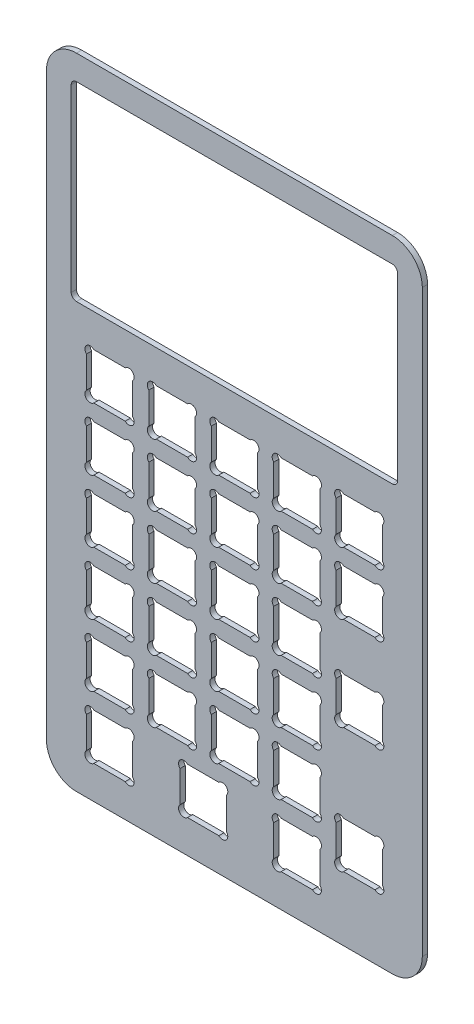
from build123d import *

# Parameters (mm, degrees)
SKETCH1_W           = 113.9
SKETCH1_H           = 193.7954
BOSS_EXTRUDE1_DEPTH = 1.5875
FILLET1_R           = 9.0875


with BuildPart() as part:
    # Sketch1 → Boss-Extrude1 (new body)
    with BuildSketch(Plane.XY):
        with Locations((-56.95, 96.8977)):
            Rectangle(SKETCH1_W, SKETCH1_H)
        with BuildLine():
            Line((-80.62263597, 118.5954), (-71.11736403, 118.5954))
            ThreePointArc((-71.11736403, 118.5954), (-68.8723, 118.5954), (-68.8723, 116.35033597))
            Line((-68.8723, 116.35033597), (-68.8723, 106.84506403))
            ThreePointArc((-68.8723, 106.84506403), (-68.8723, 104.6), (-71.11736403, 104.6))
            Line((-71.11736403, 104.6), (-80.62263597, 104.6))
            ThreePointArc((-80.62263597, 104.6), (-82.8677, 104.6), (-82.8677, 106.84506403))
            Line((-82.8677, 106.84506403), (-82.8677, 116.35033597))
            ThreePointArc((-82.8677, 116.35033597), (-82.8677, 118.5954), (-80.62263597, 118.5954))
        make_face(mode=Mode.SUBTRACT)
        with BuildLine():
            Line((-99.54263597, 118.5954), (-90.03736403, 118.5954))
            ThreePointArc((-90.03736403, 118.5954), (-87.7923, 118.5954), (-87.7923, 116.35033597))
            Line((-87.7923, 116.35033597), (-87.7923, 106.84506403))
            ThreePointArc((-87.7923, 106.84506403), (-87.7923, 104.6), (-90.03736403, 104.6))
            Line((-90.03736403, 104.6), (-99.54263597, 104.6))
            ThreePointArc((-99.54263597, 104.6), (-101.7877, 104.6), (-101.7877, 106.84506403))
            Line((-101.7877, 106.84506403), (-101.7877, 116.35033597))
            ThreePointArc((-101.7877, 116.35033597), (-101.7877, 118.5954), (-99.54263597, 118.5954))
        make_face(mode=Mode.SUBTRACT)
        with BuildLine():
            Line((-61.70263597, 118.5954), (-52.19736403, 118.5954))
            ThreePointArc((-52.19736403, 118.5954), (-49.9523, 118.5954), (-49.9523, 116.35033597))
            Line((-49.9523, 116.35033597), (-49.9523, 106.84506403))
            ThreePointArc((-49.9523, 106.84506403), (-49.9523, 104.6), (-52.19736403, 104.6))
            Line((-52.19736403, 104.6), (-61.70263597, 104.6))
            ThreePointArc((-61.70263597, 104.6), (-63.9477, 104.6), (-63.9477, 106.84506403))
            Line((-63.9477, 106.84506403), (-63.9477, 116.35033597))
            ThreePointArc((-63.9477, 116.35033597), (-63.9477, 118.5954), (-61.70263597, 118.5954))
        make_face(mode=Mode.SUBTRACT)
        with BuildLine():
            Line((-42.78263597, 118.5954), (-33.27736403, 118.5954))
            ThreePointArc((-33.27736403, 118.5954), (-31.0323, 118.5954), (-31.0323, 116.35033597))
            Line((-31.0323, 116.35033597), (-31.0323, 106.84506403))
            ThreePointArc((-31.0323, 106.84506403), (-31.0323, 104.6), (-33.27736403, 104.6))
            Line((-33.27736403, 104.6), (-42.78263597, 104.6))
            ThreePointArc((-42.78263597, 104.6), (-45.0277, 104.6), (-45.0277, 106.84506403))
            Line((-45.0277, 106.84506403), (-45.0277, 116.35033597))
            ThreePointArc((-45.0277, 116.35033597), (-45.0277, 118.5954), (-42.78263597, 118.5954))
        make_face(mode=Mode.SUBTRACT)
        with BuildLine():
            Line((-23.86263597, 118.5954), (-14.35736403, 118.5954))
            ThreePointArc((-14.35736403, 118.5954), (-12.1123, 118.5954), (-12.1123, 116.35033597))
            Line((-12.1123, 116.35033597), (-12.1123, 106.84506403))
            ThreePointArc((-12.1123, 106.84506403), (-12.1123, 104.6), (-14.35736403, 104.6))
            Line((-14.35736403, 104.6), (-23.86263597, 104.6))
            ThreePointArc((-23.86263597, 104.6), (-26.1077, 104.6), (-26.1077, 106.84506403))
            Line((-26.1077, 106.84506403), (-26.1077, 116.35033597))
            ThreePointArc((-26.1077, 116.35033597), (-26.1077, 118.5954), (-23.86263597, 118.5954))
        make_face(mode=Mode.SUBTRACT)
        with BuildLine():
            Line((-80.62263597, 99.6754), (-71.11736403, 99.6754))
            ThreePointArc((-71.11736403, 99.6754), (-68.8723, 99.6754), (-68.8723, 97.43033597))
            Line((-68.8723, 97.43033597), (-68.8723, 87.92506403))
            ThreePointArc((-68.8723, 87.92506403), (-68.8723, 85.68), (-71.11736403, 85.68))
            Line((-71.11736403, 85.68), (-80.62263597, 85.68))
            ThreePointArc((-80.62263597, 85.68), (-82.8677, 85.68), (-82.8677, 87.92506403))
            Line((-82.8677, 87.92506403), (-82.8677, 97.43033597))
            ThreePointArc((-82.8677, 97.43033597), (-82.8677, 99.6754), (-80.62263597, 99.6754))
        make_face(mode=Mode.SUBTRACT)
        with BuildLine():
            Line((-61.70263597, 99.6754), (-52.19736403, 99.6754))
            ThreePointArc((-52.19736403, 99.6754), (-49.9523, 99.6754), (-49.9523, 97.43033597))
            Line((-49.9523, 97.43033597), (-49.9523, 87.92506403))
            ThreePointArc((-49.9523, 87.92506403), (-49.9523, 85.68), (-52.19736403, 85.68))
            Line((-52.19736403, 85.68), (-61.70263597, 85.68))
            ThreePointArc((-61.70263597, 85.68), (-63.9477, 85.68), (-63.9477, 87.92506403))
            Line((-63.9477, 87.92506403), (-63.9477, 97.43033597))
            ThreePointArc((-63.9477, 97.43033597), (-63.9477, 99.6754), (-61.70263597, 99.6754))
        make_face(mode=Mode.SUBTRACT)
        with BuildLine():
            Line((-42.78263597, 99.6754), (-33.27736403, 99.6754))
            ThreePointArc((-33.27736403, 99.6754), (-31.0323, 99.6754), (-31.0323, 97.43033597))
            Line((-31.0323, 97.43033597), (-31.0323, 87.92506403))
            ThreePointArc((-31.0323, 87.92506403), (-31.0323, 85.68), (-33.27736403, 85.68))
            Line((-33.27736403, 85.68), (-42.78263597, 85.68))
            ThreePointArc((-42.78263597, 85.68), (-45.0277, 85.68), (-45.0277, 87.92506403))
            Line((-45.0277, 87.92506403), (-45.0277, 97.43033597))
            ThreePointArc((-45.0277, 97.43033597), (-45.0277, 99.6754), (-42.78263597, 99.6754))
        make_face(mode=Mode.SUBTRACT)
        with BuildLine():
            Line((-23.86263597, 99.6754), (-14.35736403, 99.6754))
            ThreePointArc((-14.35736403, 99.6754), (-12.1123, 99.6754), (-12.1123, 97.43033597))
            Line((-12.1123, 97.43033597), (-12.1123, 87.92506403))
            ThreePointArc((-12.1123, 87.92506403), (-12.1123, 85.68), (-14.35736403, 85.68))
            Line((-14.35736403, 85.68), (-23.86263597, 85.68))
            ThreePointArc((-23.86263597, 85.68), (-26.1077, 85.68), (-26.1077, 87.92506403))
            Line((-26.1077, 87.92506403), (-26.1077, 97.43033597))
            ThreePointArc((-26.1077, 97.43033597), (-26.1077, 99.6754), (-23.86263597, 99.6754))
        make_face(mode=Mode.SUBTRACT)
        with BuildLine():
            Line((-80.62263597, 80.7554), (-71.11736403, 80.7554))
            ThreePointArc((-71.11736403, 80.7554), (-68.8723, 80.7554), (-68.8723, 78.51033597))
            Line((-68.8723, 78.51033597), (-68.8723, 69.00506403))
            ThreePointArc((-68.8723, 69.00506403), (-68.8723, 66.76), (-71.11736403, 66.76))
            Line((-71.11736403, 66.76), (-80.62263597, 66.76))
            ThreePointArc((-80.62263597, 66.76), (-82.8677, 66.76), (-82.8677, 69.00506403))
            Line((-82.8677, 69.00506403), (-82.8677, 78.51033597))
            ThreePointArc((-82.8677, 78.51033597), (-82.8677, 80.7554), (-80.62263597, 80.7554))
        make_face(mode=Mode.SUBTRACT)
        with BuildLine():
            Line((-61.70263597, 80.7554), (-52.19736403, 80.7554))
            ThreePointArc((-52.19736403, 80.7554), (-49.9523, 80.7554), (-49.9523, 78.51033597))
            Line((-49.9523, 78.51033597), (-49.9523, 69.00506403))
            ThreePointArc((-49.9523, 69.00506403), (-49.9523, 66.76), (-52.19736403, 66.76))
            Line((-52.19736403, 66.76), (-61.70263597, 66.76))
            ThreePointArc((-61.70263597, 66.76), (-63.9477, 66.76), (-63.9477, 69.00506403))
            Line((-63.9477, 69.00506403), (-63.9477, 78.51033597))
            ThreePointArc((-63.9477, 78.51033597), (-63.9477, 80.7554), (-61.70263597, 80.7554))
        make_face(mode=Mode.SUBTRACT)
        with BuildLine():
            Line((-42.78263597, 80.7554), (-33.27736403, 80.7554))
            ThreePointArc((-33.27736403, 80.7554), (-31.0323, 80.7554), (-31.0323, 78.51033597))
            Line((-31.0323, 78.51033597), (-31.0323, 69.00506403))
            ThreePointArc((-31.0323, 69.00506403), (-31.0323, 66.76), (-33.27736403, 66.76))
            Line((-33.27736403, 66.76), (-42.78263597, 66.76))
            ThreePointArc((-42.78263597, 66.76), (-45.0277, 66.76), (-45.0277, 69.00506403))
            Line((-45.0277, 69.00506403), (-45.0277, 78.51033597))
            ThreePointArc((-45.0277, 78.51033597), (-45.0277, 80.7554), (-42.78263597, 80.7554))
        make_face(mode=Mode.SUBTRACT)
        with BuildLine():
            Line((-80.62263597, 61.8354), (-71.11736403, 61.8354))
            ThreePointArc((-71.11736403, 61.8354), (-68.8723, 61.8354), (-68.8723, 59.59033597))
            Line((-68.8723, 59.59033597), (-68.8723, 50.08506403))
            ThreePointArc((-68.8723, 50.08506403), (-68.8723, 47.84), (-71.11736403, 47.84))
            Line((-71.11736403, 47.84), (-80.62263597, 47.84))
            ThreePointArc((-80.62263597, 47.84), (-82.8677, 47.84), (-82.8677, 50.08506403))
            Line((-82.8677, 50.08506403), (-82.8677, 59.59033597))
            ThreePointArc((-82.8677, 59.59033597), (-82.8677, 61.8354), (-80.62263597, 61.8354))
        make_face(mode=Mode.SUBTRACT)
        with BuildLine():
            Line((-61.70263597, 61.8354), (-52.19736403, 61.8354))
            ThreePointArc((-52.19736403, 61.8354), (-49.9523, 61.8354), (-49.9523, 59.59033597))
            Line((-49.9523, 59.59033597), (-49.9523, 50.08506403))
            ThreePointArc((-49.9523, 50.08506403), (-49.9523, 47.84), (-52.19736403, 47.84))
            Line((-52.19736403, 47.84), (-61.70263597, 47.84))
            ThreePointArc((-61.70263597, 47.84), (-63.9477, 47.84), (-63.9477, 50.08506403))
            Line((-63.9477, 50.08506403), (-63.9477, 59.59033597))
            ThreePointArc((-63.9477, 59.59033597), (-63.9477, 61.8354), (-61.70263597, 61.8354))
        make_face(mode=Mode.SUBTRACT)
        with BuildLine():
            Line((-42.78263597, 61.8354), (-33.27736403, 61.8354))
            ThreePointArc((-33.27736403, 61.8354), (-31.0323, 61.8354), (-31.0323, 59.59033597))
            Line((-31.0323, 59.59033597), (-31.0323, 50.08506403))
            ThreePointArc((-31.0323, 50.08506403), (-31.0323, 47.84), (-33.27736403, 47.84))
            Line((-33.27736403, 47.84), (-42.78263597, 47.84))
            ThreePointArc((-42.78263597, 47.84), (-45.0277, 47.84), (-45.0277, 50.08506403))
            Line((-45.0277, 50.08506403), (-45.0277, 59.59033597))
            ThreePointArc((-45.0277, 59.59033597), (-45.0277, 61.8354), (-42.78263597, 61.8354))
        make_face(mode=Mode.SUBTRACT)
        with BuildLine():
            Line((-80.62263597, 42.9154), (-71.11736403, 42.9154))
            ThreePointArc((-71.11736403, 42.9154), (-68.8723, 42.9154), (-68.8723, 40.67033597))
            Line((-68.8723, 40.67033597), (-68.8723, 31.16506403))
            ThreePointArc((-68.8723, 31.16506403), (-68.8723, 28.92), (-71.11736403, 28.92))
            Line((-71.11736403, 28.92), (-80.62263597, 28.92))
            ThreePointArc((-80.62263597, 28.92), (-82.8677, 28.92), (-82.8677, 31.16506403))
            Line((-82.8677, 31.16506403), (-82.8677, 40.67033597))
            ThreePointArc((-82.8677, 40.67033597), (-82.8677, 42.9154), (-80.62263597, 42.9154))
        make_face(mode=Mode.SUBTRACT)
        with BuildLine():
            Line((-61.70263597, 42.9154), (-52.19736403, 42.9154))
            ThreePointArc((-52.19736403, 42.9154), (-49.9523, 42.9154), (-49.9523, 40.67033597))
            Line((-49.9523, 40.67033597), (-49.9523, 31.16506403))
            ThreePointArc((-49.9523, 31.16506403), (-49.9523, 28.92), (-52.19736403, 28.92))
            Line((-52.19736403, 28.92), (-61.70263597, 28.92))
            ThreePointArc((-61.70263597, 28.92), (-63.9477, 28.92), (-63.9477, 31.16506403))
            Line((-63.9477, 31.16506403), (-63.9477, 40.67033597))
            ThreePointArc((-63.9477, 40.67033597), (-63.9477, 42.9154), (-61.70263597, 42.9154))
        make_face(mode=Mode.SUBTRACT)
        with BuildLine():
            Line((-42.78263597, 42.9154), (-33.27736403, 42.9154))
            ThreePointArc((-33.27736403, 42.9154), (-31.0323, 42.9154), (-31.0323, 40.67033597))
            Line((-31.0323, 40.67033597), (-31.0323, 31.16506403))
            ThreePointArc((-31.0323, 31.16506403), (-31.0323, 28.92), (-33.27736403, 28.92))
            Line((-33.27736403, 28.92), (-42.78263597, 28.92))
            ThreePointArc((-42.78263597, 28.92), (-45.0277, 28.92), (-45.0277, 31.16506403))
            Line((-45.0277, 31.16506403), (-45.0277, 40.67033597))
            ThreePointArc((-45.0277, 40.67033597), (-45.0277, 42.9154), (-42.78263597, 42.9154))
        make_face(mode=Mode.SUBTRACT)
        with BuildLine():
            Line((-42.78263597, 23.9954), (-33.27736403, 23.9954))
            ThreePointArc((-33.27736403, 23.9954), (-31.0323, 23.9954), (-31.0323, 21.75033597))
            Line((-31.0323, 21.75033597), (-31.0323, 12.24506403))
            ThreePointArc((-31.0323, 12.24506403), (-31.0323, 10), (-33.27736403, 10))
            Line((-33.27736403, 10), (-42.78263597, 10))
            ThreePointArc((-42.78263597, 10), (-45.0277, 10), (-45.0277, 12.24506403))
            Line((-45.0277, 12.24506403), (-45.0277, 21.75033597))
            ThreePointArc((-45.0277, 21.75033597), (-45.0277, 23.9954), (-42.78263597, 23.9954))
        make_face(mode=Mode.SUBTRACT)
        with BuildLine():
            Line((-99.54263597, 99.6754), (-90.03736403, 99.6754))
            ThreePointArc((-90.03736403, 99.6754), (-87.7923, 99.6754), (-87.7923, 97.43033597))
            Line((-87.7923, 97.43033597), (-87.7923, 87.92506403))
            ThreePointArc((-87.7923, 87.92506403), (-87.7923, 85.68), (-90.03736403, 85.68))
            Line((-90.03736403, 85.68), (-99.54263597, 85.68))
            ThreePointArc((-99.54263597, 85.68), (-101.7877, 85.68), (-101.7877, 87.92506403))
            Line((-101.7877, 87.92506403), (-101.7877, 97.43033597))
            ThreePointArc((-101.7877, 97.43033597), (-101.7877, 99.6754), (-99.54263597, 99.6754))
        make_face(mode=Mode.SUBTRACT)
        with BuildLine():
            Line((-99.54263597, 80.7554), (-90.03736403, 80.7554))
            ThreePointArc((-90.03736403, 80.7554), (-87.7923, 80.7554), (-87.7923, 78.51033597))
            Line((-87.7923, 78.51033597), (-87.7923, 69.00506403))
            ThreePointArc((-87.7923, 69.00506403), (-87.7923, 66.76), (-90.03736403, 66.76))
            Line((-90.03736403, 66.76), (-99.54263597, 66.76))
            ThreePointArc((-99.54263597, 66.76), (-101.7877, 66.76), (-101.7877, 69.00506403))
            Line((-101.7877, 69.00506403), (-101.7877, 78.51033597))
            ThreePointArc((-101.7877, 78.51033597), (-101.7877, 80.7554), (-99.54263597, 80.7554))
        make_face(mode=Mode.SUBTRACT)
        with BuildLine():
            Line((-99.54263597, 61.8354), (-90.03736403, 61.8354))
            ThreePointArc((-90.03736403, 61.8354), (-87.7923, 61.8354), (-87.7923, 59.59033597))
            Line((-87.7923, 59.59033597), (-87.7923, 50.08506403))
            ThreePointArc((-87.7923, 50.08506403), (-87.7923, 47.84), (-90.03736403, 47.84))
            Line((-90.03736403, 47.84), (-99.54263597, 47.84))
            ThreePointArc((-99.54263597, 47.84), (-101.7877, 47.84), (-101.7877, 50.08506403))
            Line((-101.7877, 50.08506403), (-101.7877, 59.59033597))
            ThreePointArc((-101.7877, 59.59033597), (-101.7877, 61.8354), (-99.54263597, 61.8354))
        make_face(mode=Mode.SUBTRACT)
        with BuildLine():
            Line((-99.54263597, 42.9154), (-90.03736403, 42.9154))
            ThreePointArc((-90.03736403, 42.9154), (-87.7923, 42.9154), (-87.7923, 40.67033597))
            Line((-87.7923, 40.67033597), (-87.7923, 31.16506403))
            ThreePointArc((-87.7923, 31.16506403), (-87.7923, 28.92), (-90.03736403, 28.92))
            Line((-90.03736403, 28.92), (-99.54263597, 28.92))
            ThreePointArc((-99.54263597, 28.92), (-101.7877, 28.92), (-101.7877, 31.16506403))
            Line((-101.7877, 31.16506403), (-101.7877, 40.67033597))
            ThreePointArc((-101.7877, 40.67033597), (-101.7877, 42.9154), (-99.54263597, 42.9154))
        make_face(mode=Mode.SUBTRACT)
        with BuildLine():
            Line((-99.54263597, 23.9954), (-90.03736403, 23.9954))
            ThreePointArc((-90.03736403, 23.9954), (-87.7923, 23.9954), (-87.7923, 21.75033597))
            Line((-87.7923, 21.75033597), (-87.7923, 12.24506403))
            ThreePointArc((-87.7923, 12.24506403), (-87.7923, 10), (-90.03736403, 10))
            Line((-90.03736403, 10), (-99.54263597, 10))
            ThreePointArc((-99.54263597, 10), (-101.7877, 10), (-101.7877, 12.24506403))
            Line((-101.7877, 12.24506403), (-101.7877, 21.75033597))
            ThreePointArc((-101.7877, 21.75033597), (-101.7877, 23.9954), (-99.54263597, 23.9954))
        make_face(mode=Mode.SUBTRACT)
        with BuildLine():
            Line((-71.16263597, 23.9954), (-61.65736403, 23.9954))
            ThreePointArc((-61.65736403, 23.9954), (-59.4123, 23.9954), (-59.4123, 21.75033597))
            Line((-59.4123, 21.75033597), (-59.4123, 12.24506403))
            ThreePointArc((-59.4123, 12.24506403), (-59.4123, 10), (-61.65736403, 10))
            Line((-61.65736403, 10), (-71.16263597, 10))
            ThreePointArc((-71.16263597, 10), (-73.4077, 10), (-73.4077, 12.24506403))
            Line((-73.4077, 12.24506403), (-73.4077, 21.75033597))
            ThreePointArc((-73.4077, 21.75033597), (-73.4077, 23.9954), (-71.16263597, 23.9954))
        make_face(mode=Mode.SUBTRACT)
        with BuildLine():
            Line((-23.86263597, 33.4554), (-14.35736403, 33.4554))
            ThreePointArc((-14.35736403, 33.4554), (-12.1123, 33.4554), (-12.1123, 31.21033597))
            Line((-12.1123, 31.21033597), (-12.1123, 21.70506403))
            ThreePointArc((-12.1123, 21.70506403), (-12.1123, 19.46), (-14.35736403, 19.46))
            Line((-14.35736403, 19.46), (-23.86263597, 19.46))
            ThreePointArc((-23.86263597, 19.46), (-26.1077, 19.46), (-26.1077, 21.70506403))
            Line((-26.1077, 21.70506403), (-26.1077, 31.21033597))
            ThreePointArc((-26.1077, 31.21033597), (-26.1077, 33.4554), (-23.86263597, 33.4554))
        make_face(mode=Mode.SUBTRACT)
        with BuildLine():
            Line((-23.86263597, 71.2954), (-14.35736403, 71.2954))
            ThreePointArc((-14.35736403, 71.2954), (-12.1123, 71.2954), (-12.1123, 69.05033597))
            Line((-12.1123, 69.05033597), (-12.1123, 59.54506403))
            ThreePointArc((-12.1123, 59.54506403), (-12.1123, 57.3), (-14.35736403, 57.3))
            Line((-14.35736403, 57.3), (-23.86263597, 57.3))
            ThreePointArc((-23.86263597, 57.3), (-26.1077, 57.3), (-26.1077, 59.54506403))
            Line((-26.1077, 59.54506403), (-26.1077, 69.05033597))
            ThreePointArc((-26.1077, 69.05033597), (-26.1077, 71.2954), (-23.86263597, 71.2954))
        make_face(mode=Mode.SUBTRACT)
        with BuildLine():
            Line((-104.8125, 186.2954), (-9.0875, 186.2954))
            ThreePointArc((-9.0875, 186.2954), (-7.964967985, 185.830432015), (-7.5, 184.7079))
            Line((-7.5, 184.7079), (-7.5, 130.1829))
            ThreePointArc((-7.5, 130.1829), (-7.964967985, 129.060367985), (-9.0875, 128.5954))
            Line((-9.0875, 128.5954), (-104.8125, 128.5954))
            ThreePointArc((-104.8125, 128.5954), (-105.935032015, 129.060367985), (-106.4, 130.1829))
            Line((-106.4, 130.1829), (-106.4, 184.7079))
            ThreePointArc((-106.4, 184.7079), (-105.935032015, 185.830432015), (-104.8125, 186.2954))
        make_face(mode=Mode.SUBTRACT)
    extrude(amount=BOSS_EXTRUDE1_DEPTH)

    # Fillet1
    fillet1_edges = [part.edges().sort_by_distance(p)[0] for p in [
        (0, 0, 0.79375),
        (-113.9, 0, 0.79375),
        (-113.9, 193.7954, 0.79375),
        (0, 193.7954, 0.79375),
    ]]
    fillet(fillet1_edges, radius=FILLET1_R)


solid = part.part
